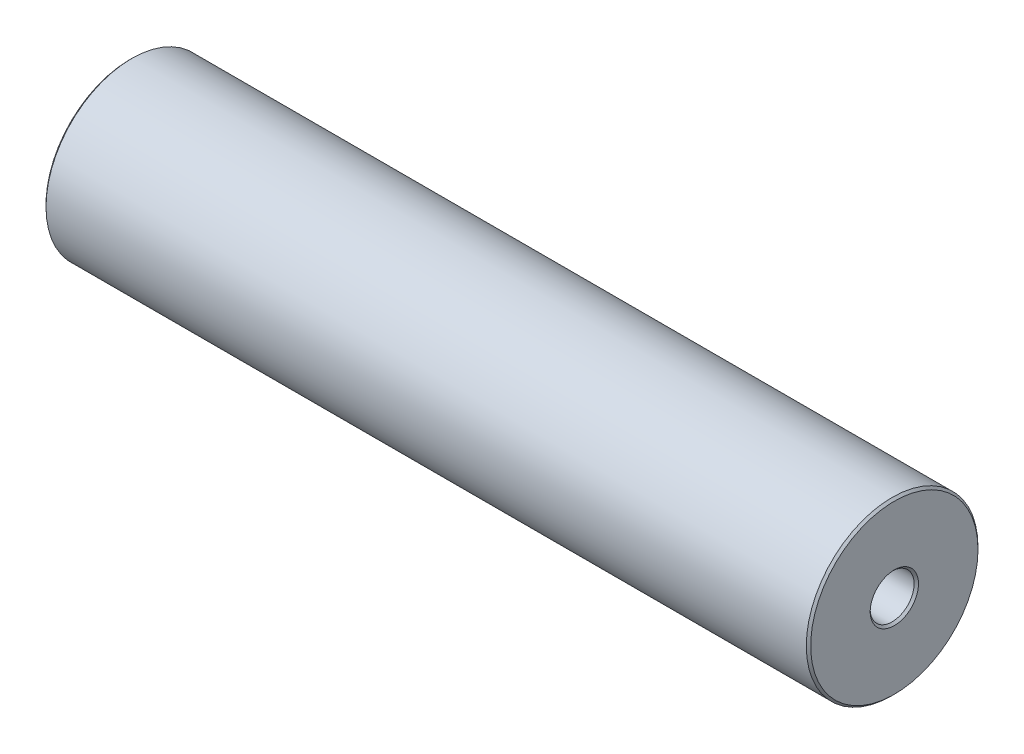
from build123d import *

# Parameters (mm, degrees)
SKETCH2_R                             = 9.980949939
BOSS_EXTRUDE1_DEPTH                   = 44.45
F_1_4_20_TAPPED_HOLE1_D               = 5.1054
F_1_4_20_TAPPED_HOLE1_DEPTH           = 16.51
F_1_4_20_TAPPED_HOLE1_TIP             = 1.533816902
F_1_4_20_TAPPED_HOLE1_ON_FACE_2_D     = 5.1054
F_1_4_20_TAPPED_HOLE1_ON_FACE_2_DEPTH = 16.51
F_1_4_20_TAPPED_HOLE1_ON_FACE_2_TIP   = 1.533816902
F_1_4_20_TAPPED_HOLE1_ON_FACE_3_D     = 5.1054
F_1_4_20_TAPPED_HOLE1_ON_FACE_3_DEPTH = 16.51
F_1_4_20_TAPPED_HOLE1_ON_FACE_3_TIP   = 1.533816902
CHAMFER1_SIZE                         = 0.254


with BuildPart() as part:
    # Sketch2 → Boss-Extrude1 (new body, symmetric)
    with BuildSketch(Plane(origin=(0, 0, 0), x_dir=(0, 0, -1), z_dir=(1, 0, 0))):
        Circle(SKETCH2_R)
    extrude(amount=BOSS_EXTRUDE1_DEPTH, both=True)

    # 1/4-20 Tapped Hole1
    with Locations(Plane(origin=(-44.45, 0, 0), x_dir=(0, 0, -1), z_dir=(-1, 0, 0))):
        with Locations((0, 0)):
            Hole(F_1_4_20_TAPPED_HOLE1_D / 2, depth=F_1_4_20_TAPPED_HOLE1_DEPTH)
            with Locations((0, 0, -(F_1_4_20_TAPPED_HOLE1_DEPTH + F_1_4_20_TAPPED_HOLE1_TIP / 2))):  # 118° drill point
                Cone(0, F_1_4_20_TAPPED_HOLE1_D / 2, F_1_4_20_TAPPED_HOLE1_TIP, mode=Mode.SUBTRACT)

    # 1/4-20 Tapped Hole1 on face 2
    with Locations(Plane(origin=(14.956085126, -44.657762317, 0), x_dir=(0, 0, -1), z_dir=(-1, 0, 0))):
        with Locations((0, 0)):
            Hole(F_1_4_20_TAPPED_HOLE1_ON_FACE_2_D / 2, depth=F_1_4_20_TAPPED_HOLE1_ON_FACE_2_DEPTH)
            with Locations((0, 0, -(F_1_4_20_TAPPED_HOLE1_ON_FACE_2_DEPTH + F_1_4_20_TAPPED_HOLE1_ON_FACE_2_TIP / 2))):  # 118° drill point
                Cone(0, F_1_4_20_TAPPED_HOLE1_ON_FACE_2_D / 2, F_1_4_20_TAPPED_HOLE1_ON_FACE_2_TIP, mode=Mode.SUBTRACT)

    # 1/4-20 Tapped Hole1 on face 3
    with Locations(Plane(origin=(44.45, 0, 0), x_dir=(0, 0, 1), z_dir=(1, 0, 0))):
        with Locations((0, 0)):
            Hole(F_1_4_20_TAPPED_HOLE1_ON_FACE_3_D / 2, depth=F_1_4_20_TAPPED_HOLE1_ON_FACE_3_DEPTH)
            with Locations((0, 0, -(F_1_4_20_TAPPED_HOLE1_ON_FACE_3_DEPTH + F_1_4_20_TAPPED_HOLE1_ON_FACE_3_TIP / 2))):  # 118° drill point
                Cone(0, F_1_4_20_TAPPED_HOLE1_ON_FACE_3_D / 2, F_1_4_20_TAPPED_HOLE1_ON_FACE_3_TIP, mode=Mode.SUBTRACT)

    # Chamfer1
    chamfer1_edges = [part.edges().sort_by_distance(p)[0] for p in [
        (-44.45, 0, 9.980949939),
        (44.45, 0, 9.980949939),
        (-44.45, 0, -2.5527),
        (44.45, 0, 2.5527),
    ]]
    chamfer(chamfer1_edges, length=CHAMFER1_SIZE)


solid = part.part
